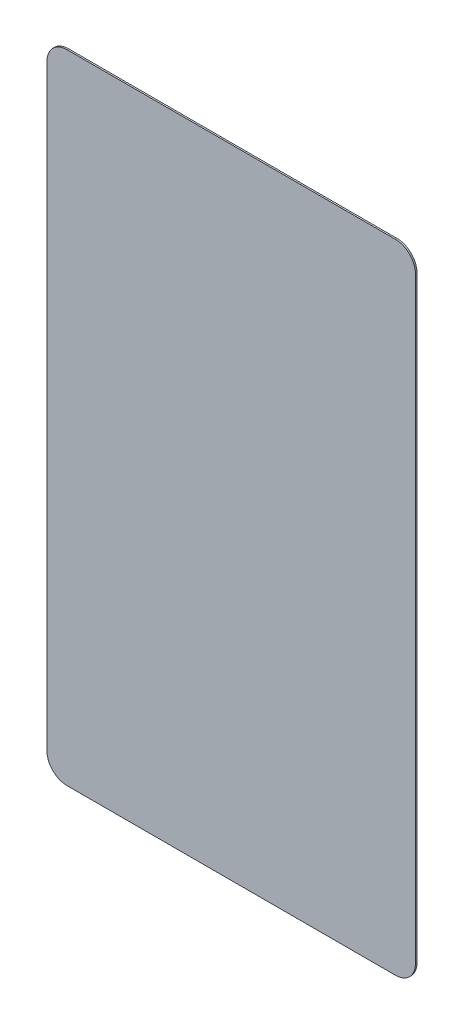
from build123d import *

# Parameters (mm, degrees)
BOSS_EXTRUDE1_DEPTH = 0.254


with BuildPart() as part:
    # Sketch1 → Boss-Extrude1 (new body)
    with BuildSketch(Plane.XY):
        with BuildLine():
            Line((-26.19375, 101.6), (26.19375, 101.6))
            ThreePointArc((26.19375, 101.6), (28.43881403, 100.67006403), (29.36875, 98.425))
            Line((29.36875, 98.425), (29.36875, 3.175))
            ThreePointArc((29.36875, 3.175), (28.43881403, 0.92993597), (26.19375, 0))
            Line((26.19375, 0), (-26.19375, 0))
            ThreePointArc((-26.19375, 0), (-28.43881403, 0.92993597), (-29.36875, 3.175))
            Line((-29.36875, 3.175), (-29.36875, 98.425))
            ThreePointArc((-29.36875, 98.425), (-28.43881403, 100.67006403), (-26.19375, 101.6))
        make_face()
    extrude(amount=-BOSS_EXTRUDE1_DEPTH)


solid = part.part
